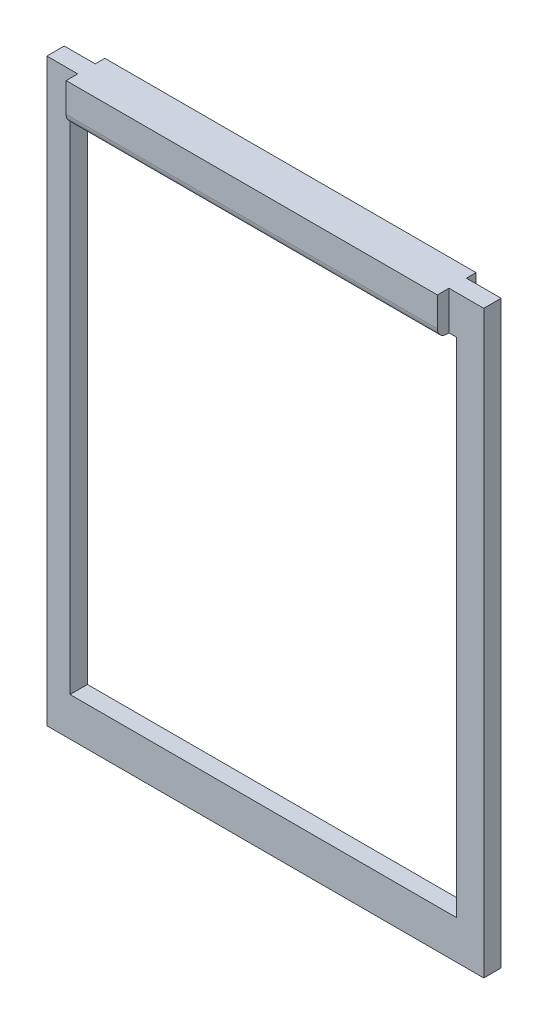
from build123d import *

# Parameters (mm, degrees)
SKETCH2_W                = 56.5
SKETCH2_H                = 75
SKETCH2_W_2              = 50
SKETCH2_H_2              = 65
BOSS_EXTRUDE1_DEPTH      = 2.25
SKETCH3_W                = 48
SKETCH3_H                = 5
BOSS_EXTRUDE2_DEPTH      = 1.5
BOSS_EXTRUDE3_DEPTH      = 1.5
BOSS_EXTRUDE3_DEPTH_BACK = 3.5
SKETCH3_4_W              = 48
SKETCH3_4_H              = 5
FILLET3_R                = 1.2


with BuildPart() as part:
    # Sketch2 → Boss-Extrude1 (new body)
    with BuildSketch(Plane.XY):
        with Locations((28.25, 37.5)):
            Rectangle(SKETCH2_W, SKETCH2_H)
        with Locations((28, 37.5)):
            Rectangle(SKETCH2_W_2, SKETCH2_H_2, mode=Mode.SUBTRACT)
    extrude(amount=BOSS_EXTRUDE1_DEPTH)

    # Sketch3 → Boss-Extrude2 (add)
    with BuildSketch(Plane.XY.offset(2.25)):
        with Locations((28, 72.5)):
            Rectangle(SKETCH3_W, SKETCH3_H)
    extrude(amount=BOSS_EXTRUDE2_DEPTH)

    # Sketch3_4 → Boss-Extrude3 (add, two sides: drawn at the far end of the back side and taken through both)
    with BuildSketch(Plane.XY.offset(2.25).offset(-BOSS_EXTRUDE3_DEPTH_BACK)):
        with Locations((28, 72.5)):
            Rectangle(SKETCH3_4_W, SKETCH3_4_H)
    extrude(amount=BOSS_EXTRUDE3_DEPTH + BOSS_EXTRUDE3_DEPTH_BACK)

    # Fillet3
    fillet3_edges = [part.edges().sort_by_distance(p)[0] for p in [
        (28, 70, -1.25),
        (28, 70, 3.75),
    ]]
    fillet(fillet3_edges, radius=FILLET3_R)


solid = part.part
